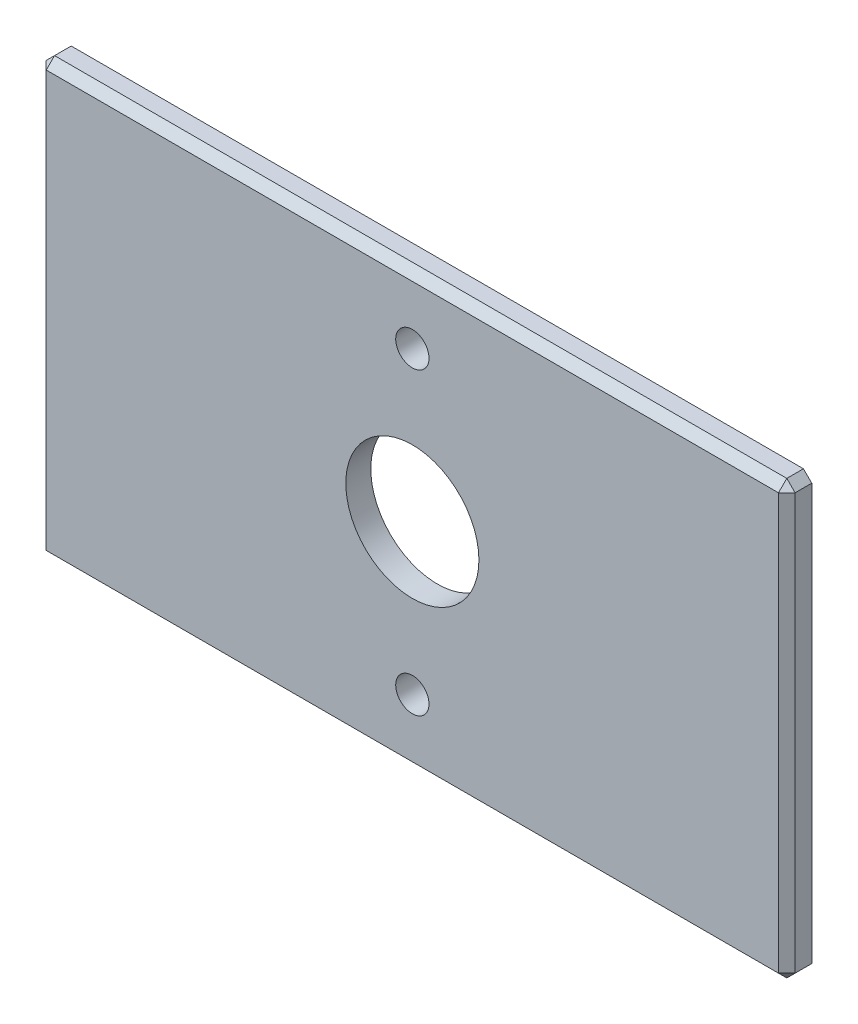
from build123d import *

# Parameters (mm, degrees)
SKETCH1_W           = 45
SKETCH1_H           = 26
SKETCH1_R           = 4
SKETCH1_R_2         = 1
BOSS_EXTRUDE1_DEPTH = 0.75
CHAMFER1_SIZE       = 0.5


with BuildPart() as part:
    # Sketch1 → Boss-Extrude1 (new body, symmetric)
    with BuildSketch(Plane.XY):
        Rectangle(SKETCH1_W, SKETCH1_H)
        Circle(SKETCH1_R, mode=Mode.SUBTRACT)
        with Locations((0, 9)):
            Circle(SKETCH1_R_2, mode=Mode.SUBTRACT)
        with Locations((0, -9)):
            Circle(SKETCH1_R_2, mode=Mode.SUBTRACT)
    extrude(amount=BOSS_EXTRUDE1_DEPTH, both=True)

    # Chamfer1
    chamfer1_edges = [part.edges().sort_by_distance(p)[0] for p in [
        (-22.5, 0, 0.75),
        (0, -13, 0.75),
        (22.5, 0, 0.75),
        (22.5, -13, 0),
        (-22.5, -13, 0),
        (-22.5, 13, 0),
        (22.5, 13, 0),
        (0, 13, 0.75),
    ]]
    chamfer(chamfer1_edges, length=CHAMFER1_SIZE)


solid = part.part
